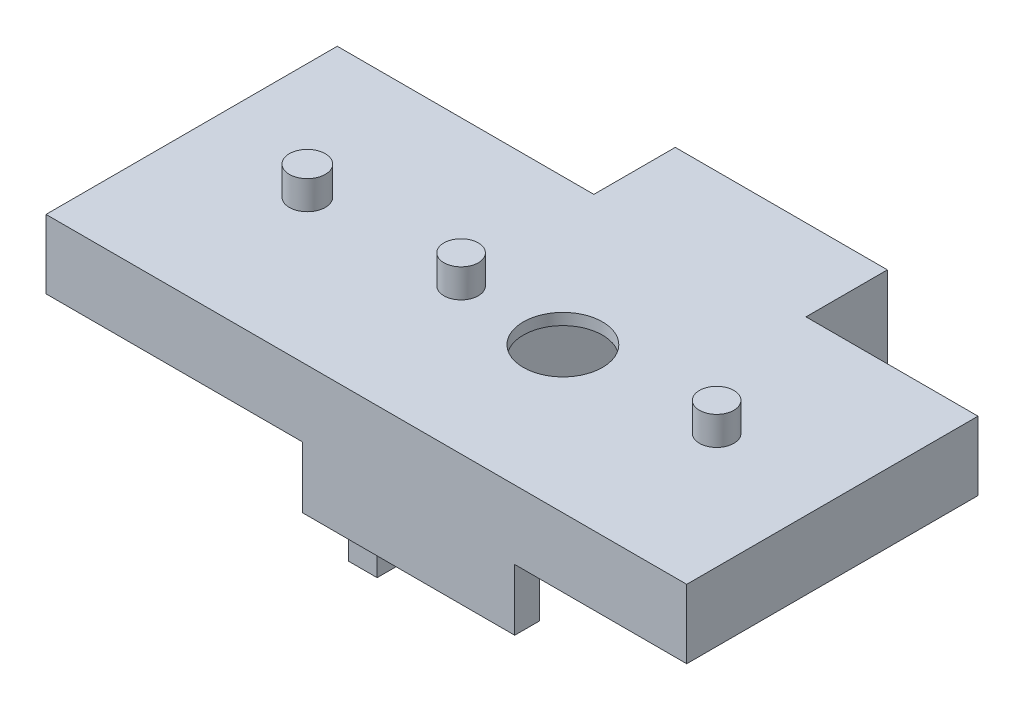
from build123d import *

# Parameters (mm, degrees)
SKETCH3_W            = 57
SKETCH3_H            = 34
SKETCH3_R            = 2.2
BOSS_EXTRUDE2_DEPTH  = 5
BOSS_EXTRUDE3_DEPTH  = 32
SKETCH5_R            = 6.9
CUT_EXTRUDE1_DEPTH   = 19
BOSS_EXTRUDE4_DEPTH  = 8
SKETCH7_W            = 6
SKETCH7_H            = 4.5
BOSS_EXTRUDE5_DEPTH  = 39.5
BOSS_EXTRUDE6_DEPTH  = 32
BOSS_EXTRUDE7_DEPTH  = 32
SKETCH11_W           = 6
SKETCH11_H           = 8.410531804
BOSS_EXTRUDE8_DEPTH  = 58.155109
SKETCH12_W           = 6
SKETCH12_H           = 1.5
BOSS_EXTRUDE9_DEPTH  = 9
SKETCH13_W           = 50.8
SKETCH13_H           = 12
BOSS_EXTRUDE10_DEPTH = 30
SKETCH14_W           = 50.8
SKETCH14_H           = 12
BOSS_EXTRUDE11_DEPTH = 44.75
SKETCH15_R           = 3
SKETCH15_R_2         = 3.129089935
BOSS_EXTRUDE12_DEPTH = 5


with BuildPart() as part:
    # Sketch3 → Boss-Extrude2 (new body)
    with BuildSketch(Plane(origin=(0, 0, 0), x_dir=(0, 0, -1), z_dir=(1, 0, 0))):
        Rectangle(SKETCH3_W, SKETCH3_H)
        with Locations((-24.8, -3.1)):
            Circle(SKETCH3_R, mode=Mode.SUBTRACT)
        with Locations((-24.8, -13)):
            Circle(SKETCH3_R, mode=Mode.SUBTRACT)
        with Locations((24.2, -3.1)):
            Circle(SKETCH3_R, mode=Mode.SUBTRACT)
        with Locations((24.2, -13)):
            Circle(SKETCH3_R, mode=Mode.SUBTRACT)
    extrude(amount=BOSS_EXTRUDE2_DEPTH)

    # Sketch4 → Boss-Extrude3 (add)
    with BuildSketch(Plane(origin=(5, 0, 0), x_dir=(0, 0, -1), z_dir=(1, 0, 0))):
        Polygon((-28.5, 17), (12, 17), (12, 15), (-20, 15), (-20, 10.5), (-28.5, 10.5), align=None)
    extrude(amount=BOSS_EXTRUDE3_DEPTH)

    # Sketch5 → Cut-Extrude1 (cut)
    with BuildSketch(Plane(origin=(0, 17, 0), x_dir=(1, 0, 0), z_dir=(0, 1, 0))):
        with Locations((20, -11.1)):
            Circle(SKETCH5_R)
    extrude(amount=-CUT_EXTRUDE1_DEPTH, mode=Mode.SUBTRACT)

    # Sketch6 → Boss-Extrude4 (add)
    with BuildSketch(Plane.XY.offset(28.5)):
        Polygon((0, 17), (37, 17), (37, 10.5), (5, 10.5), (5, -5.696050601), (0, -5.696050601), align=None)
    extrude(amount=BOSS_EXTRUDE4_DEPTH)

    # Sketch7 → Boss-Extrude5 (add)
    with BuildSketch(Plane(origin=(0, 0, 20), x_dir=(-1, 0, 0), z_dir=(0, 0, -1))):
        with Locations((-34, 12.75)):
            Rectangle(SKETCH7_W, SKETCH7_H)
    extrude(amount=BOSS_EXTRUDE5_DEPTH)

    # Sketch8 → Boss-Extrude6 (add)
    with BuildSketch(Plane(origin=(5, 0, 0), x_dir=(0, 0, -1), z_dir=(1, 0, 0))):
        Polygon((-36.5, -5.696050601), (-32.171374704, -5.696050601), (-32.171374704, 2.089468196), (-29.655108528, 2.089468196), (-29.655108528, 10.5), (-32.171374704, 10.5), (-36.5, 10.5), align=None)
    extrude(amount=BOSS_EXTRUDE6_DEPTH)

    # Sketch9 → Boss-Extrude7 (add)
    with BuildSketch(Plane(origin=(5, 0, 0), x_dir=(0, 0, -1), z_dir=(1, 0, 0))):
        Polygon((12, 17), (28.5, 17), (28.5, 12), (19.5, 12), (19.5, 15), (12, 15), align=None)
    extrude(amount=BOSS_EXTRUDE7_DEPTH)

    # Sketch11 → Boss-Extrude8 (add)
    with BuildSketch(Plane(origin=(0, 0, 29.655108528), x_dir=(-1, 0, 0), z_dir=(0, 0, -1))):
        with Locations((-34, 6.294734098)):
            Rectangle(SKETCH11_W, SKETCH11_H)
    extrude(amount=BOSS_EXTRUDE8_DEPTH)

    # Sketch12 → Boss-Extrude9 (add)
    with BuildSketch(Plane(origin=(0, 0, -19.5), x_dir=(-1, 0, 0), z_dir=(0, 0, -1))):
        with Locations((-34, 11.25)):
            Rectangle(SKETCH12_W, SKETCH12_H)
    extrude(amount=BOSS_EXTRUDE9_DEPTH)

    # Sketch13 → Boss-Extrude10 (add)
    with BuildSketch(Plane(origin=(37, 0, 0), x_dir=(0, 0, -1), z_dir=(1, 0, 0))):
        with Locations((-11.1, 11)):
            Rectangle(SKETCH13_W, SKETCH13_H)
    extrude(amount=BOSS_EXTRUDE10_DEPTH)

    # Sketch14 → Boss-Extrude11 (add)
    with BuildSketch(Plane.ZY):
        with Locations((11.1, 11)):
            Rectangle(SKETCH14_W, SKETCH14_H)
    extrude(amount=BOSS_EXTRUDE11_DEPTH)

    # Sketch15 → Boss-Extrude12 (add)
    with BuildSketch(Plane(origin=(0, 17, 0), x_dir=(1, 0, 0), z_dir=(0, 1, 0))):
        with Locations((2.25, -11.1)):
            Circle(SKETCH15_R)
        with Locations((46.82, -11.1)):
            Circle(SKETCH15_R)
        with Locations((-24.57, -11.1)):
            Circle(SKETCH15_R_2)
    extrude(amount=BOSS_EXTRUDE12_DEPTH)


solid = part.part
